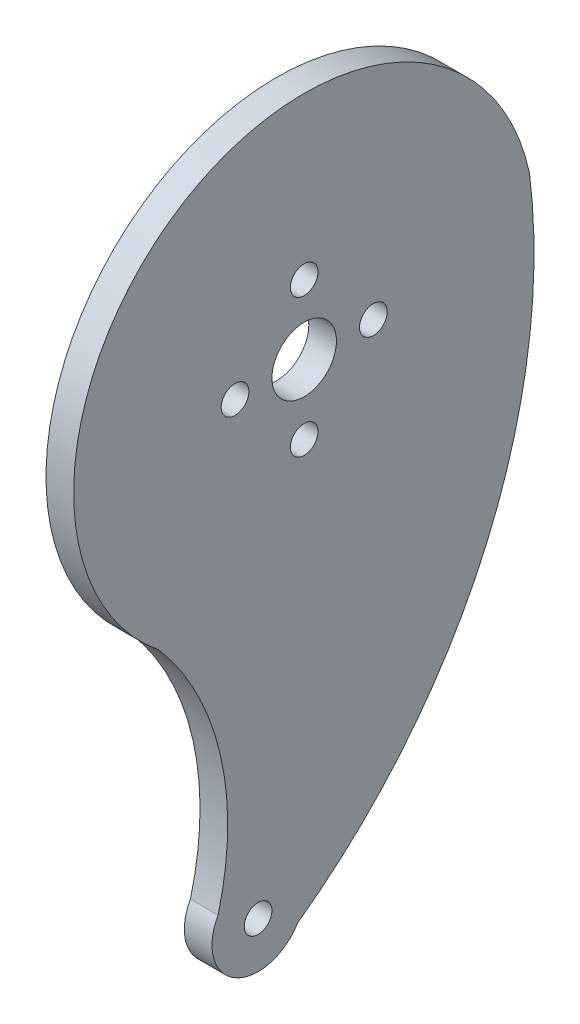
from build123d import *

# Parameters (mm, degrees)
CROQUIS1_R              = 3.5
CROQUIS1_R_2            = 1.5
SALIENTE_EXTRUIR1_DEPTH = 3


with BuildPart() as part:
    # Croquis1 → Saliente-Extruir1 (new body)
    with BuildSketch(Plane(origin=(0, 0, 0), x_dir=(0, 0, -1), z_dir=(1, 0, 0))):
        with BuildLine():
            ThreePointArc((24.429451457, 5.310546254), (-13.102683121, 21.291305621), (-15.74927408, -19.415467184))
            ThreePointArc((-15.74927408, -19.415467184), (-9.07160693, -32.67265708), (-9.338328875, -47.514260157))
            ThreePointArc((-9.338328875, -47.514260157), (-7.527733898, -54.313995983), (-0.71074339, -52.569489781))
            ThreePointArc((-0.71074339, -52.569489781), (19.815359954, -27.085163099), (24.429451457, 5.310546254))
        make_face()
        Circle(CROQUIS1_R, mode=Mode.SUBTRACT)
        with Locations((-5, -50)):
            Circle(CROQUIS1_R_2, mode=Mode.SUBTRACT)
        with Locations((-7.5, 0)):
            Circle(CROQUIS1_R_2, mode=Mode.SUBTRACT)
        with Locations((0, 7.5)):
            Circle(CROQUIS1_R_2, mode=Mode.SUBTRACT)
        with Locations((7.5, 0)):
            Circle(CROQUIS1_R_2, mode=Mode.SUBTRACT)
        with Locations((0, -7.5)):
            Circle(CROQUIS1_R_2, mode=Mode.SUBTRACT)
    extrude(amount=SALIENTE_EXTRUIR1_DEPTH)


solid = part.part
